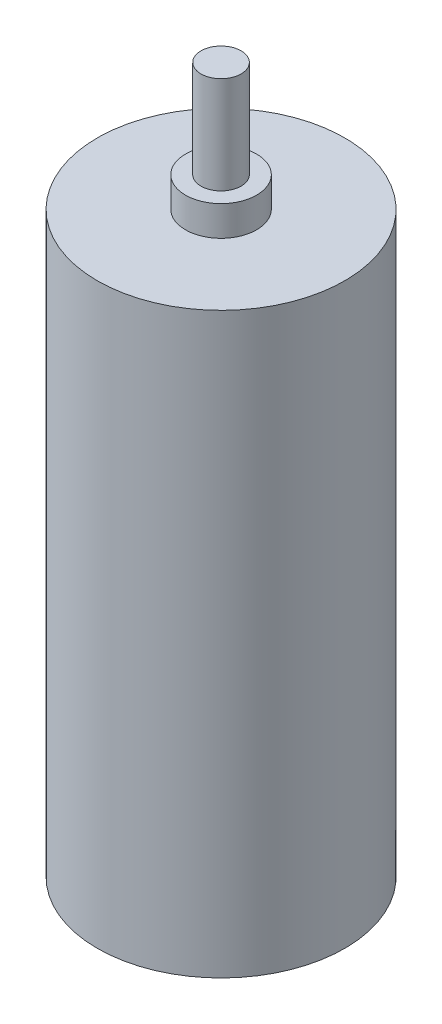
from build123d import *

# Parameters (mm, degrees)
SKETCH1_R           = 12.35
BOSS_EXTRUDE1_DEPTH = 57.7
SKETCH2_R           = 3.55
BOSS_EXTRUDE2_DEPTH = 3
SKETCH3_R           = 2
BOSS_EXTRUDE3_DEPTH = 9.7


with BuildPart() as part:
    # Sketch1 → Boss-Extrude1 (new body)
    with BuildSketch(Plane(origin=(0, 0, 0), x_dir=(1, 0, 0), z_dir=(0, 1, 0))):
        Circle(SKETCH1_R)
    extrude(amount=BOSS_EXTRUDE1_DEPTH)

    # Sketch2 → Boss-Extrude2 (add)
    with BuildSketch(Plane(origin=(0, 57.7, 0), x_dir=(1, 0, 0), z_dir=(0, 1, 0))):
        Circle(SKETCH2_R)
    extrude(amount=BOSS_EXTRUDE2_DEPTH)

    # Sketch3 → Boss-Extrude3 (add)
    with BuildSketch(Plane(origin=(0, 60.7, 0), x_dir=(1, 0, 0), z_dir=(0, 1, 0))):
        Circle(SKETCH3_R)
    extrude(amount=BOSS_EXTRUDE3_DEPTH)


solid = part.part
